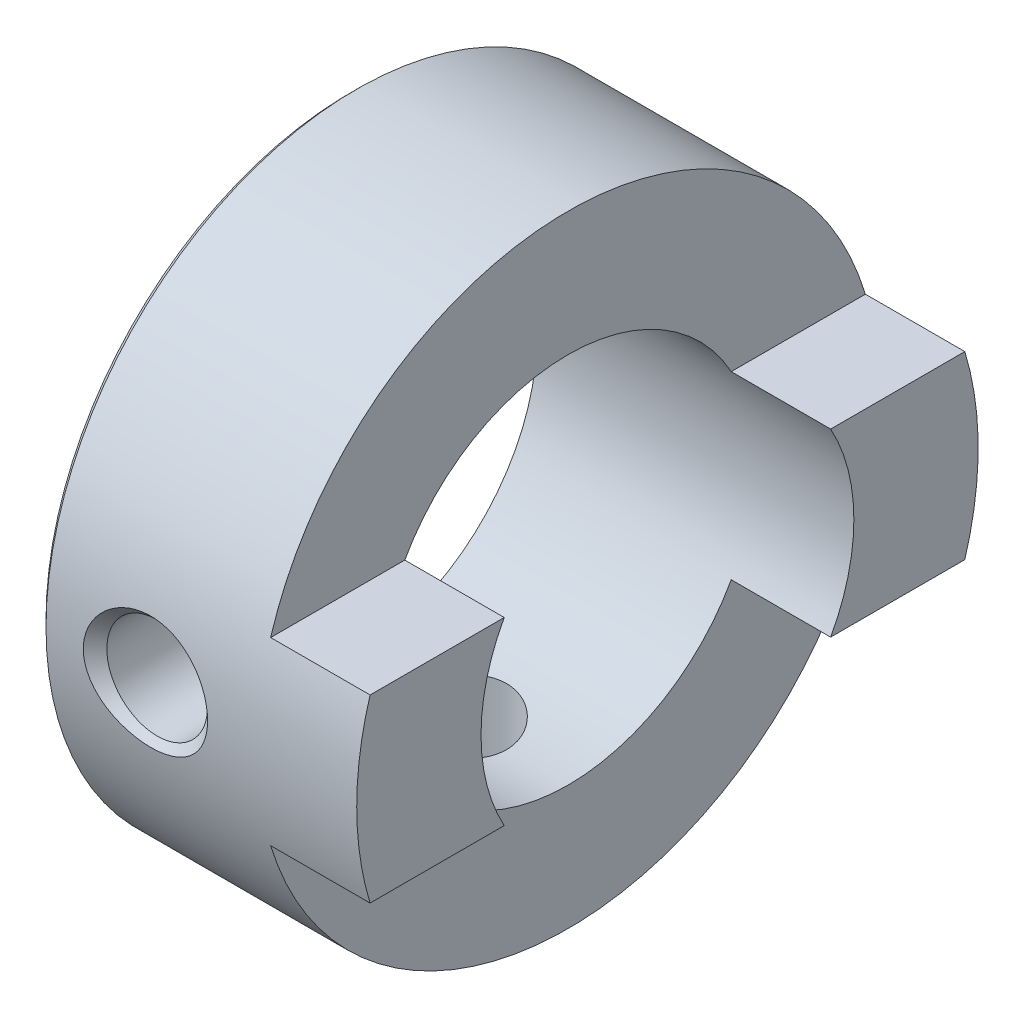
from build123d import *

# Parameters (mm, degrees)
SKETCH2_W          = 22
SKETCH2_H          = 21
SKETCH2_W_2        = 20
SKETCH2_H_2        = 5.8
CUT_EXTRUDE1_DEPTH = 3.2


with BuildPart() as part:
    # Sketch1 → Revolve1 (revolve)
    with BuildSketch(Plane.XY):
        Polygon((0, 9.8), (0, 6), (10.2, 6), (10.2, 10), (0.2, 10), align=None)
    revolve(axis=Axis((10.2, 0, 0), (-1, 0, 0)))

    # Sketch2 → Cut-Extrude1 (cut)
    with BuildSketch(Plane(origin=(10.2, 0, 0), x_dir=(0, 0, -1), z_dir=(1, 0, 0))):
        Rectangle(SKETCH2_W, SKETCH2_H)
        Rectangle(SKETCH2_W_2, SKETCH2_H_2, mode=Mode.SUBTRACT)
    extrude(amount=-CUT_EXTRUDE1_DEPTH, mode=Mode.SUBTRACT)

    # Sketch3 → Cut-Revolve1 (revolve, cut)
    with BuildSketch(Plane(origin=(3.4, 0, 0), x_dir=(0, 0, -1), z_dir=(1, 0, 0))):
        Polygon((-10, 0), (-10, 2), (-9.621, 1.621), (0, 1.621), (0, 0), align=None)
    revolve(axis=Axis((3.4, 0, 0), (0, 0, 1)), mode=Mode.SUBTRACT)

    # Sketch4 → Cut-Revolve2 (revolve, cut)
    with BuildSketch(Plane(origin=(3.4, 0, 0), x_dir=(0, 0, -1), z_dir=(1, 0, 0))):
        Polygon((0, -10), (-2, -10), (-1.621, -9.621), (-1.621, 0), (0, 0), align=None)
    revolve(axis=Axis((3.4, 0, 0), (0, -1, 0)), mode=Mode.SUBTRACT)


solid = part.part
